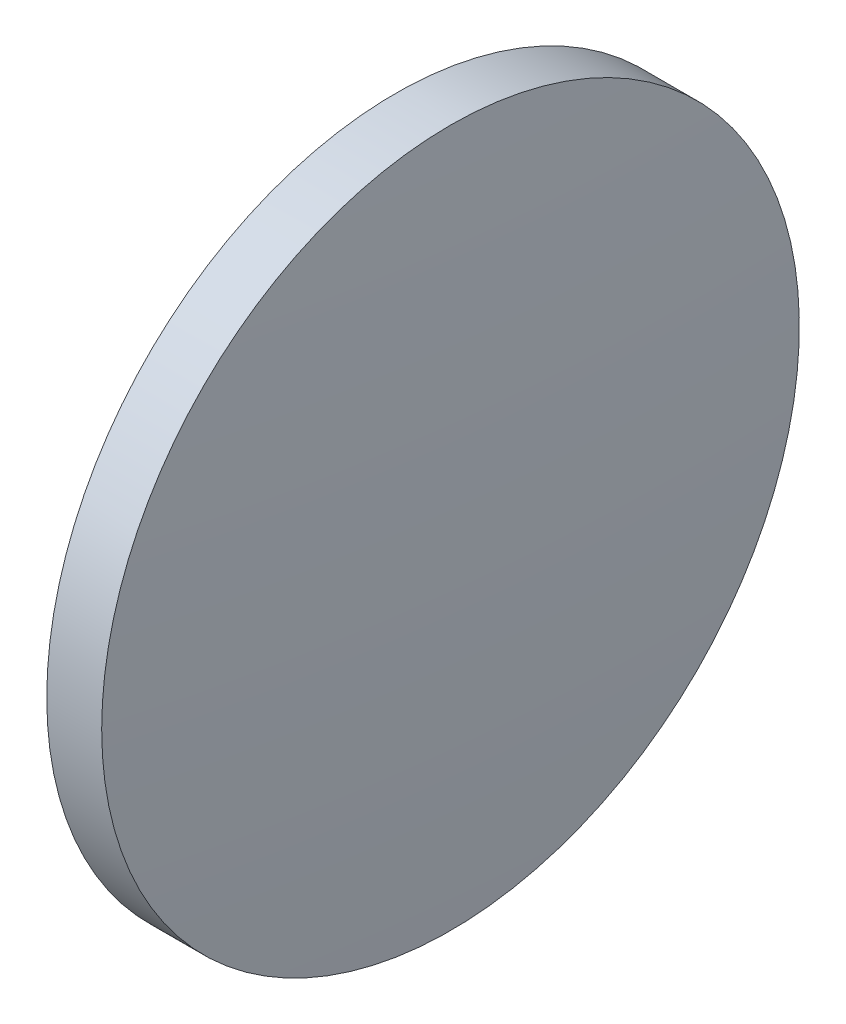
from build123d import *


with BuildPart() as part:
    # 草图1 → 旋转1 (revolve)
    with BuildSketch(Plane.XY):
        with BuildLine():
            Line((477.322086179, 184.577382555), (477.322086179, 197.277382555))
            Line((477.322086179, 197.277382555), (479.322086179, 197.277382555))
            ThreePointArc((479.322086179, 197.277382555), (479.622061391, 190.930531381), (479.722086179, 184.577382555))
            Line((479.722086179, 184.577382555), (477.322086179, 184.577382555))
        make_face()
    revolve(axis=Axis((471.583868143, 184.577382555, 0), (1, 0, 0)))


solid = part.part
